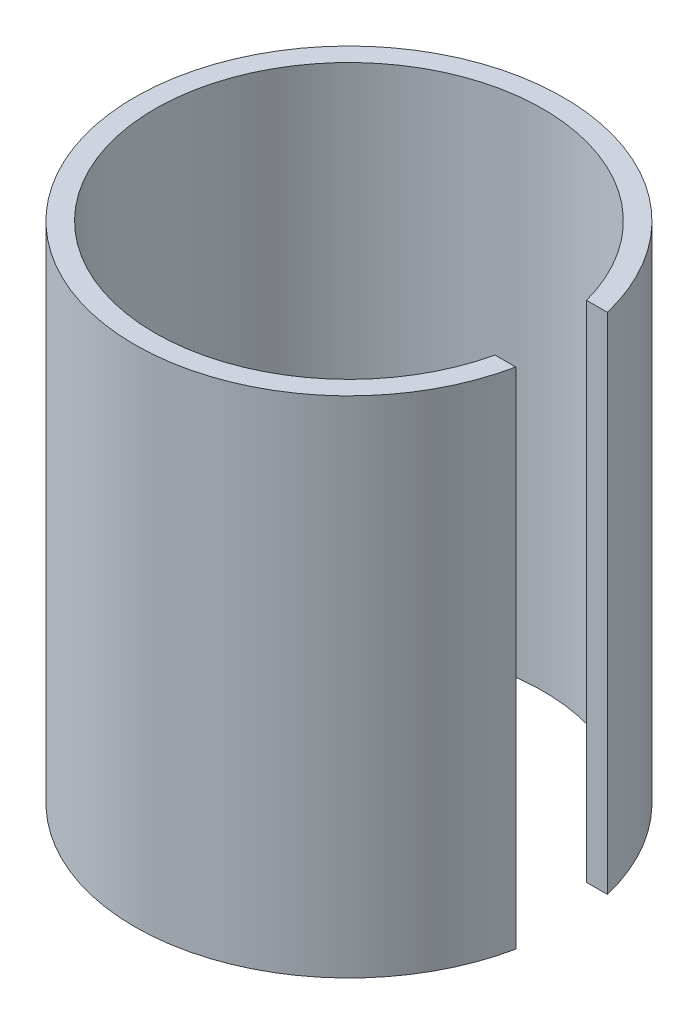
from build123d import *

# Parameters (mm, degrees)
RESSALTO_EXTRUS_O1_DEPTH = 200


with BuildPart() as part:
    # Esboço1 → Ressalto-extrusão1 (new body)
    with BuildSketch(Plane(origin=(0, 0, 0), x_dir=(1, 0, 0), z_dir=(0, 1, 0))):
        with BuildLine():
            Line((75.059208884, -17.094636578), (83.263277621, -17.094636578))
            ThreePointArc((83.263277621, -17.094636578), (-84.988092882, -1.422697563), (82.644458717, 19.871926011))
            Line((82.644458717, 19.871926011), (74.372158733, 19.871926011))
            ThreePointArc((74.372158733, 19.871926011), (-76.967948487, -1.430504675), (75.059208884, -17.094636578))
        make_face()
    extrude(amount=RESSALTO_EXTRUS_O1_DEPTH)


solid = part.part
